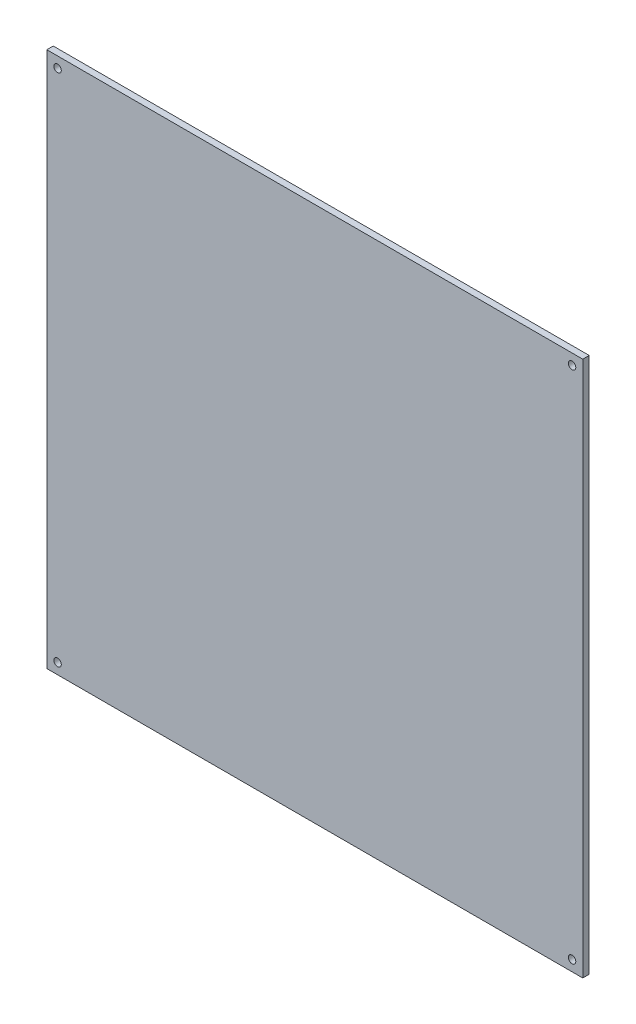
from build123d import *

# Parameters (mm, degrees)
SKETCH1_W           = 250
SKETCH1_H           = 250
BOSS_EXTRUDE1_DEPTH = 3
SKETCH3_R           = 1.75
CUT_EXTRUDE1_DEPTH  = 3


with BuildPart() as part:
    # Sketch1 → Boss-Extrude1 (new body)
    with BuildSketch(Plane.XY):
        Rectangle(SKETCH1_W, SKETCH1_H)
    extrude(amount=BOSS_EXTRUDE1_DEPTH)

    # Sketch3 → Cut-Extrude1 (cut)
    with BuildSketch(Plane.XY.offset(3)):
        with Locations((-120, 120)):
            Circle(SKETCH3_R)
        with Locations((120, 120)):
            Circle(SKETCH3_R)
        with Locations((-120, -120)):
            Circle(SKETCH3_R)
        with Locations((120, -120)):
            Circle(SKETCH3_R)
    extrude(amount=-CUT_EXTRUDE1_DEPTH, mode=Mode.SUBTRACT)


solid = part.part
